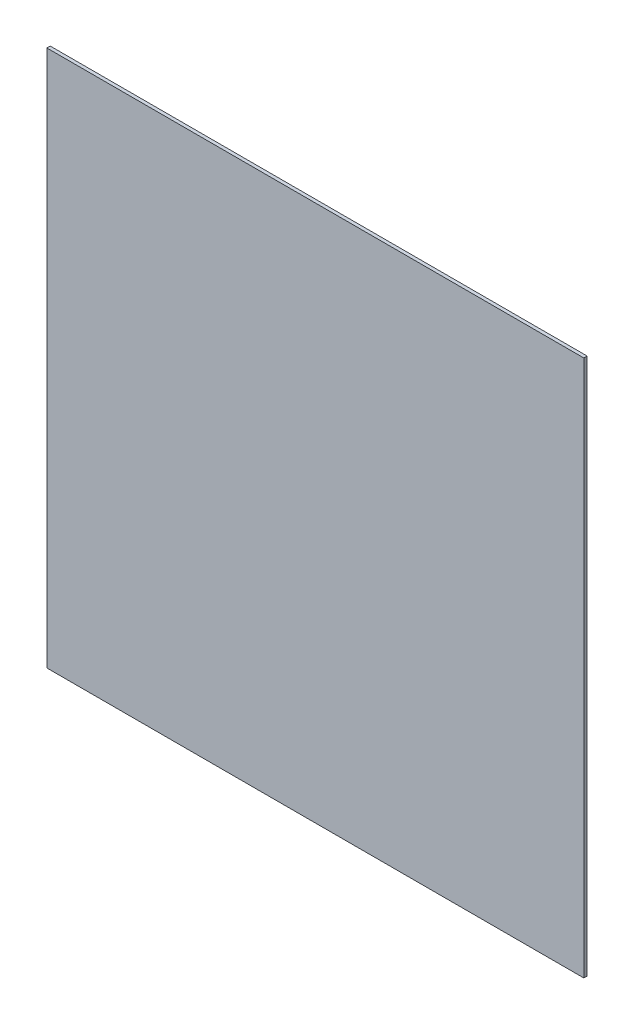
from build123d import *

# Parameters (mm, degrees)
SKETCH1_W           = 320
SKETCH1_H           = 320
BOSS_EXTRUDE1_DEPTH = 3.5
CHAMFER1_SIZE       = 1.5


with BuildPart() as part:
    # Sketch1 → Boss-Extrude1 (new body)
    with BuildSketch(Plane.XY):
        Rectangle(SKETCH1_W, SKETCH1_H)
    extrude(amount=BOSS_EXTRUDE1_DEPTH)

    # Chamfer1
    chamfer1_edges = [part.edges().sort_by_distance(p)[0] for p in [
        (0, -160, 0),
        (-160, 0, 0),
        (0, 160, 0),
        (160, 0, 0),
    ]]
    chamfer(chamfer1_edges, length=CHAMFER1_SIZE)


solid = part.part
